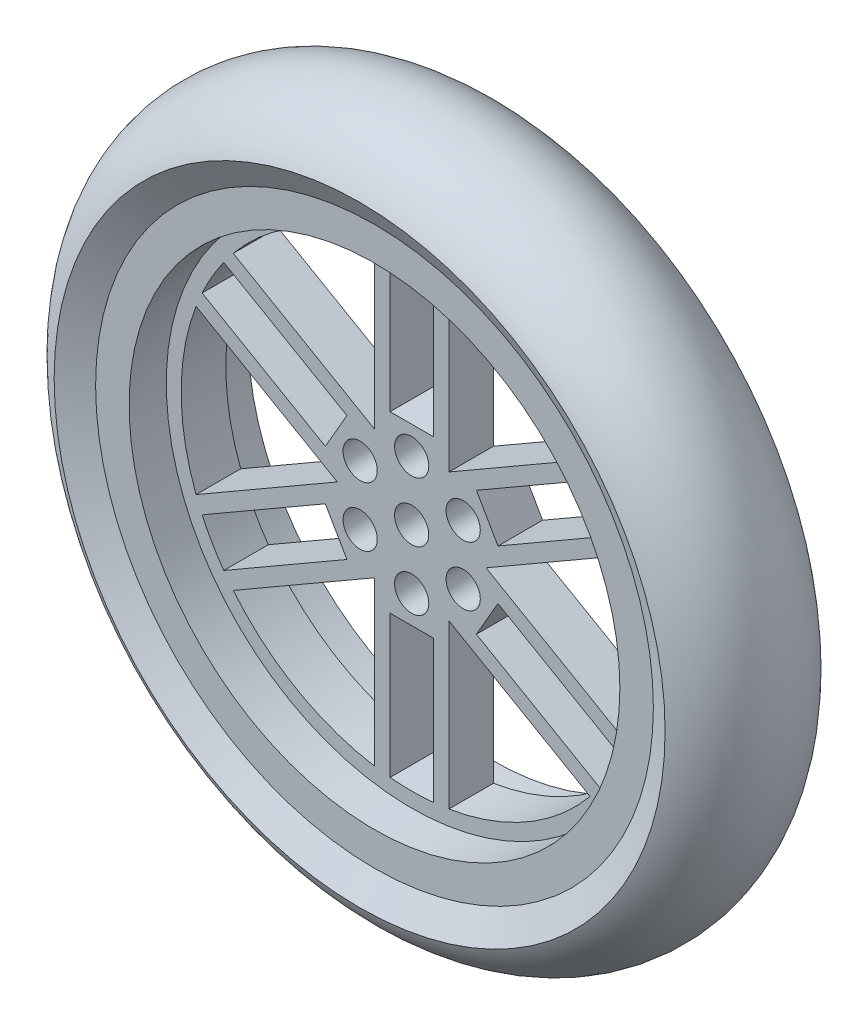
from build123d import *

# Parameters (mm, degrees)
SKETCH_2_R          = 37.505158637
SKETCH_2_R_2        = 2.3
EXTRUDE_2_DEPTH     = 8
SKETCH_3_R          = 33
CUT_EXTRUDE_1_DEPTH = 5
CUT_EXTRUDE_START   = -16
SKETCH_3_2_R        = 33
CUT_EXTRUDE_2_DEPTH = 5


with BuildPart() as part:
    # Sketch 1 → Revolve 1 (revolve)
    with BuildSketch(Plane(origin=(0, 0, 0), x_dir=(0, 0, -1), z_dir=(1, 0, 0))):
        with BuildLine():
            Line((-8, 37.505158637), (8, 37.505158637))
            Line((8, 37.505158637), (10, 41.082575695))
            ThreePointArc((10, 41.082575695), (0, 47.5), (-10, 41.082575695))
            Line((-10, 41.082575695), (-8, 37.505158637))
        make_face()
    revolve(axis=Axis((0, 0, 15.4), (0, 0, -1)))

    # Sketch 2 → Extrude 2 (add, symmetric)
    with BuildSketch(Plane.XY):
        Circle(SKETCH_2_R)
        Circle(SKETCH_2_R_2, mode=Mode.SUBTRACT)
        with Locations((0, 8)):
            Circle(SKETCH_2_R_2, mode=Mode.SUBTRACT)
        with Locations((6.92820323, 4)):
            Circle(SKETCH_2_R_2, mode=Mode.SUBTRACT)
        with Locations((6.92820323, -4)):
            Circle(SKETCH_2_R_2, mode=Mode.SUBTRACT)
        with Locations((0, -8)):
            Circle(SKETCH_2_R_2, mode=Mode.SUBTRACT)
        with Locations((-6.92820323, -4)):
            Circle(SKETCH_2_R_2, mode=Mode.SUBTRACT)
        with Locations((-6.92820323, 4)):
            Circle(SKETCH_2_R_2, mode=Mode.SUBTRACT)
        with BuildLine():
            Line((5, 30.594117082), (5, 8.660254038))
            Line((5, 8.660254038), (23.995282599, 19.62718556))
            ThreePointArc((23.995282599, 19.62718556), (15.5, 26.846787517), (5, 30.594117082))
        make_face(mode=Mode.SUBTRACT)
        with BuildLine():
            Line((10, 0), (28.995282599, -10.966931522))
            ThreePointArc((28.995282599, -10.966931522), (31, 0), (28.995282599, 10.966931522))
            Line((28.995282599, 10.966931522), (10, 0))
        make_face(mode=Mode.SUBTRACT)
        with BuildLine():
            Line((5, -8.660254038), (5, -30.594117082))
            ThreePointArc((5, -30.594117082), (15.5, -26.846787517), (23.995282599, -19.62718556))
            Line((23.995282599, -19.62718556), (5, -8.660254038))
        make_face(mode=Mode.SUBTRACT)
        with BuildLine():
            Line((-5, -8.660254038), (-23.995282599, -19.62718556))
            ThreePointArc((-23.995282599, -19.62718556), (-15.5, -26.846787517), (-5, -30.594117082))
            Line((-5, -30.594117082), (-5, -8.660254038))
        make_face(mode=Mode.SUBTRACT)
        with BuildLine():
            Line((-10, 0), (-28.995282599, 10.966931522))
            ThreePointArc((-28.995282599, 10.966931522), (-31, 0), (-28.995282599, -10.966931522))
            Line((-28.995282599, -10.966931522), (-10, 0))
        make_face(mode=Mode.SUBTRACT)
        with BuildLine():
            Line((-5, 8.660254038), (-5, 30.594117082))
            ThreePointArc((-5, 30.594117082), (-15.5, 26.846787517), (-23.995282599, 19.62718556))
            Line((-23.995282599, 19.62718556), (-5, 8.660254038))
        make_face(mode=Mode.SUBTRACT)
        with BuildLine():
            Line((-2.90470199, 30.863614603), (-2.90470199, 11.729037589))
            Line((-2.90470199, 11.729037589), (2.90470199, 11.729037589))
            Line((2.90470199, 11.729037589), (2.90470199, 30.863614603))
            ThreePointArc((2.90470199, 30.863614603), (0, 31), (-2.90470199, 30.863614603))
        make_face(mode=Mode.SUBTRACT)
        with BuildLine():
            Line((8.705293519, 8.380064508), (11.609995509, 3.34897308))
            Line((11.609995509, 3.34897308), (28.181025294, 12.916261587))
            ThreePointArc((28.181025294, 12.916261587), (26.846787517, 15.5), (25.276323303, 17.947353015))
            Line((25.276323303, 17.947353015), (8.705293519, 8.380064508))
        make_face(mode=Mode.SUBTRACT)
        with BuildLine():
            Line((11.609995509, -3.34897308), (8.705293519, -8.380064508))
            Line((8.705293519, -8.380064508), (25.276323303, -17.947353015))
            ThreePointArc((25.276323303, -17.947353015), (26.846787517, -15.5), (28.181025294, -12.916261587))
            Line((28.181025294, -12.916261587), (11.609995509, -3.34897308))
        make_face(mode=Mode.SUBTRACT)
        with BuildLine():
            Line((2.90470199, -11.729037589), (-2.90470199, -11.729037589))
            Line((-2.90470199, -11.729037589), (-2.90470199, -30.863614603))
            ThreePointArc((-2.90470199, -30.863614603), (0, -31), (2.90470199, -30.863614603))
            Line((2.90470199, -30.863614603), (2.90470199, -11.729037589))
        make_face(mode=Mode.SUBTRACT)
        with BuildLine():
            Line((-8.705293519, -8.380064508), (-11.609995509, -3.34897308))
            Line((-11.609995509, -3.34897308), (-28.181025294, -12.916261587))
            ThreePointArc((-28.181025294, -12.916261587), (-26.846787517, -15.5), (-25.276323303, -17.947353015))
            Line((-25.276323303, -17.947353015), (-8.705293519, -8.380064508))
        make_face(mode=Mode.SUBTRACT)
        with BuildLine():
            Line((-11.609995509, 3.34897308), (-8.705293519, 8.380064508))
            Line((-8.705293519, 8.380064508), (-25.276323303, 17.947353015))
            ThreePointArc((-25.276323303, 17.947353015), (-26.846787517, 15.5), (-28.181025294, 12.916261587))
            Line((-28.181025294, 12.916261587), (-11.609995509, 3.34897308))
        make_face(mode=Mode.SUBTRACT)
    extrude(amount=EXTRUDE_2_DEPTH, both=True)

    # Sketch 3 → Cut-Extrude 1 (cut)
    with BuildSketch(Plane.XY.offset(8)):
        Circle(SKETCH_3_R)
    extrude(amount=-CUT_EXTRUDE_1_DEPTH, mode=Mode.SUBTRACT)

    # Sketch 3_2 → Cut-Extrude 2 (cut)
    with BuildSketch(Plane.XY.offset(8).offset(CUT_EXTRUDE_START)):
        Circle(SKETCH_3_2_R)
    extrude(amount=CUT_EXTRUDE_2_DEPTH, mode=Mode.SUBTRACT)


solid = part.part
